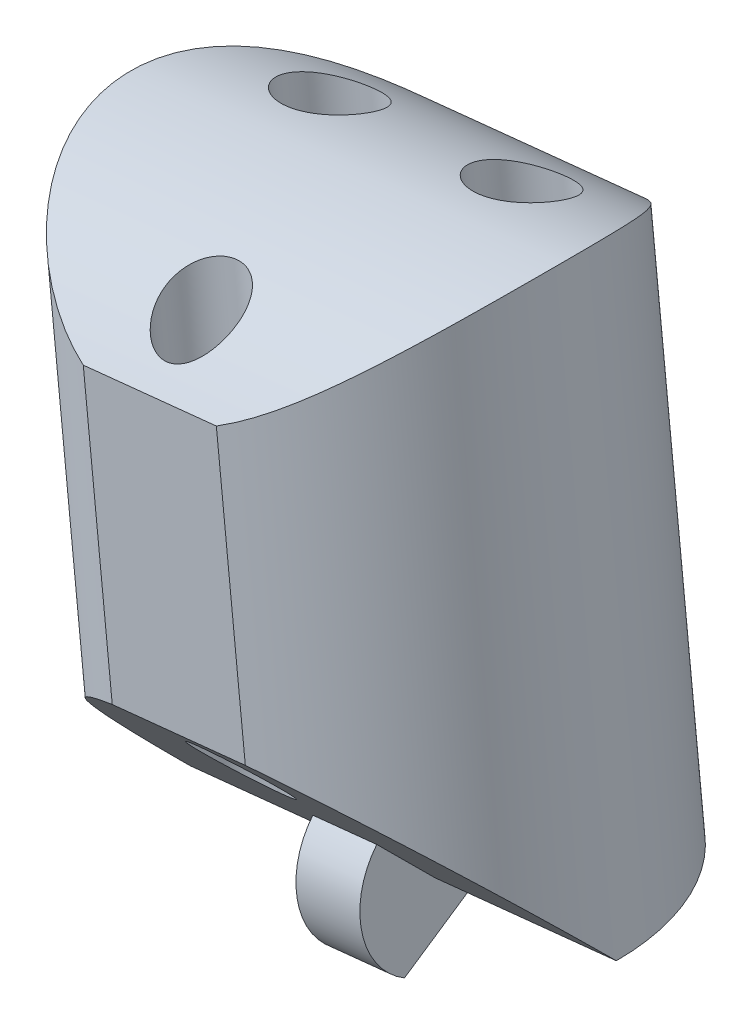
from build123d import *

# Parameters (mm, degrees)
SKETCH3_R               = 8
BOSS_EXTRUDE1_DEPTH     = 21.614736842
CUT_EXTRUDE1_DEPTH      = 11.217678336
CUT_EXTRUDE1_DEPTH_BACK = 11.217678336
CUT_EXTRUDE2_DEPTH      = 11.204574664
CUT_EXTRUDE2_DEPTH_BACK = 11.204574665
BOSS_EXTRUDE3_DEPTH     = 1.2
SKETCH8_R               = 1.6
SKETCH8_R_2             = 1.4
CUT_EXTRUDE3_DEPTH      = 25.957729977
CUT_EXTRUDE3_DEPTH_BACK = 2.513887999
CUT_EXTRUDE4_DEPTH      = 24.128624841


with BuildPart() as part:
    # Sketch3 → Boss-Extrude1 (new body)
    with BuildSketch(Plane(origin=(-12.082314344, 217.636022384, 0), x_dir=(-0.994665758, -0.103150523, 0), z_dir=(0.103150523, -0.994665758, 0))):
        Circle(SKETCH3_R)
    extrude(amount=BOSS_EXTRUDE1_DEPTH)

    # Sketch4 → Cut-Extrude1 (cut, two sides)
    with BuildSketch(Plane(origin=(10.375761543, 1.076004901, 0), x_dir=(0.103150523, -0.994665758, 0), z_dir=(-0.994665758, -0.103150523, 0))) as cut_extrude1_sk:
        with BuildLine():
            Line((-217.721396158, 8), (-213.721396158, 8))
            ThreePointArc((-213.721396158, 8), (-217.59367935, 0), (-213.721396158, -8))
            Line((-213.721396158, -8), (-217.721396158, -8))
            Line((-217.721396158, -8), (-217.721396158, 8))
        make_face()
    extrude(amount=CUT_EXTRUDE1_DEPTH, mode=Mode.SUBTRACT)
    extrude(cut_extrude1_sk.sketch, amount=-CUT_EXTRUDE1_DEPTH_BACK, mode=Mode.SUBTRACT)

    # Sketch5 → Cut-Extrude2 (cut, two sides)
    with BuildSketch(Plane(origin=(10.375761543, 1.076004901, 0), x_dir=(0.103150523, -0.994665758, 0), z_dir=(-0.994665758, -0.103150523, 0))) as cut_extrude2_sk:
        Polygon((-196.106659316, 0), (-204.106659316, 8), (-196.106659316, 8), align=None)
    extrude(amount=CUT_EXTRUDE2_DEPTH, mode=Mode.SUBTRACT)
    extrude(cut_extrude2_sk.sketch, amount=-CUT_EXTRUDE2_DEPTH_BACK, mode=Mode.SUBTRACT)

    # Sketch7 → Boss-Extrude3 (add, symmetric)
    with BuildSketch(Plane(origin=(10.375761543, 1.076004901, 0), x_dir=(0.103150523, -0.994665758, 0), z_dir=(-0.994665758, -0.103150523, 0))):
        with BuildLine():
            Line((-198.086558303, 1.979898987), (-196.106659316, 0))
            Line((-196.106659316, 0), (-196.106659316, -2.8))
            Line((-196.106659316, -2.8), (-193.681788185, 1.4))
            ThreePointArc((-193.681788185, 1.4), (-195.741185977, 2.776045612), (-198.086558303, 1.979898987))
        make_face()
    extrude(amount=BOSS_EXTRUDE3_DEPTH, both=True)

    # Sketch8 → Cut-Extrude3 (cut, two sides)
    with BuildSketch(Plane(origin=(-12.082314344, 217.636022384, 0), x_dir=(-0.994665758, -0.103150523, 0), z_dir=(0.103150523, -0.994665758, 0))) as cut_extrude3_sk:
        with Locations((-3.6, 3)):
            Circle(SKETCH8_R)
        with Locations((3.6, 3)):
            Circle(SKETCH8_R)
        with Locations((0, -5.5)):
            Circle(SKETCH8_R_2)
    extrude(amount=CUT_EXTRUDE3_DEPTH, mode=Mode.SUBTRACT)
    extrude(cut_extrude3_sk.sketch, amount=-CUT_EXTRUDE3_DEPTH_BACK, mode=Mode.SUBTRACT)

    # Sketch9 → Cut-Extrude4 (cut, through all)
    with BuildSketch(Plane(origin=(-20.228504477, 195.060578884, 0), x_dir=(0.994665758, 0.103150523, 0), z_dir=(0.103150523, -0.994665758, 0))):
        with BuildLine():
            Line((7.933405986, -7.6), (12.929404385, -7.6))
            ThreePointArc((12.929404385, -7.6), (10.431405186, -8), (7.933405986, -7.6))
        make_face()
        with BuildLine():
            Line((7.933405986, 7.6), (12.929404385, 7.6))
            ThreePointArc((12.929404385, 7.6), (10.431405186, 8), (7.933405986, 7.6))
        make_face()
    extrude(amount=-CUT_EXTRUDE4_DEPTH, mode=Mode.SUBTRACT)


solid = part.part
